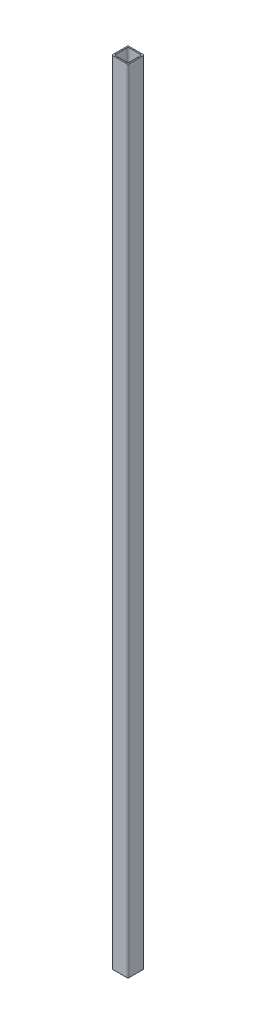
from build123d import *

# Parameters (mm, degrees)
BOSS_EXTRUDE1_DEPTH = 1200
SKETCH2_W           = 101.895059676
SKETCH2_H           = 138.127514373
CUT_EXTRUDE1_DEPTH  = 220


with BuildPart() as part:
    # Sketch1 → Boss-Extrude1 (new body)
    with BuildSketch(Plane(origin=(0, 0, 0), x_dir=(1, 0, 0), z_dir=(0, 1, 0))):
        with BuildLine():
            Line((-9, -10), (9, -10))
            ThreePointArc((9, -10), (9.707106781, -9.707106781), (10, -9))
            Line((10, -9), (10, 9))
            ThreePointArc((10, 9), (9.707106781, 9.707106781), (9, 10))
            Line((9, 10), (-9, 10))
            ThreePointArc((-9, 10), (-9.707106781, 9.707106781), (-10, 9))
            Line((-10, 9), (-10, -9))
            ThreePointArc((-10, -9), (-9.707106781, -9.707106781), (-9, -10))
        make_face()
        with BuildLine():
            Line((-7.5, -8.5), (7.5, -8.5))
            ThreePointArc((7.5, -8.5), (8.207106781, -8.207106781), (8.5, -7.5))
            Line((8.5, -7.5), (8.5, 7.5))
            ThreePointArc((8.5, 7.5), (8.207106781, 8.207106781), (7.5, 8.5))
            Line((7.5, 8.5), (-7.5, 8.5))
            ThreePointArc((-7.5, 8.5), (-8.207106781, 8.207106781), (-8.5, 7.5))
            Line((-8.5, 7.5), (-8.5, -7.5))
            ThreePointArc((-8.5, -7.5), (-8.207106781, -8.207106781), (-7.5, -8.5))
        make_face(mode=Mode.SUBTRACT)
    extrude(amount=BOSS_EXTRUDE1_DEPTH)

    # Sketch2 → Cut-Extrude1 (cut)
    with BuildSketch(Plane.XZ):
        with Locations((4.315799724, -16.6218454)):
            Rectangle(SKETCH2_W, SKETCH2_H)
    extrude(amount=-CUT_EXTRUDE1_DEPTH, mode=Mode.SUBTRACT)


solid = part.part
